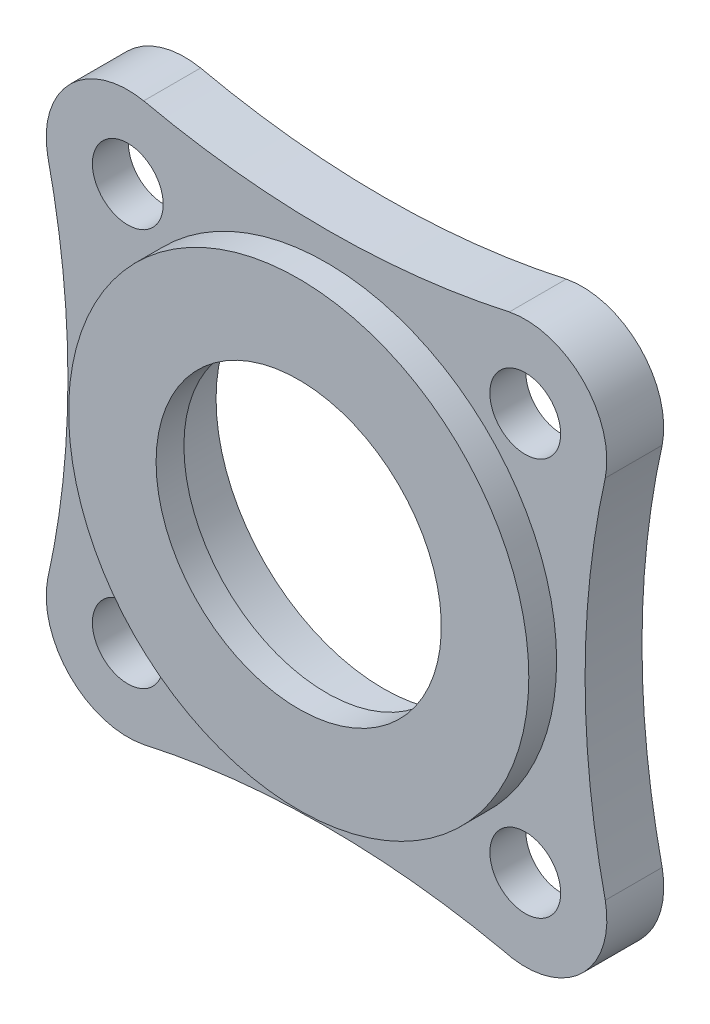
from build123d import *

# Parameters (mm, degrees)
SKETCH1_R           = 3.385
SKETCH1_R_2         = 16
BOSS_EXTRUDE1_DEPTH = 5.44
SKETCH2_R           = 6.5
CUT_EXTRUDE1_DEPTH  = 2
SKETCH3_R           = 22
BOSS_EXTRUDE2_DEPTH = 2.66
SKETCH4_R           = 13.635
CUT_EXTRUDE2_DEPTH  = 3.66


with BuildPart() as part:
    # Sketch1 → Boss-Extrude1 (new body)
    with BuildSketch(Plane.XY):
        with BuildLine():
            ThreePointArc((-17.15500238, -26.5786804), (-0.168836143, -24.722579211), (16.825003911, -26.507055409))
            ThreePointArc((16.825003911, -26.507055409), (24.281605458, -24.760439823), (26.649977107, -17.477419272))
            ThreePointArc((26.649977107, -17.477419272), (24.722401047, 0.0008954), (26.650274279, 17.479177295))
            ThreePointArc((26.650274279, 17.479177295), (24.514793015, 24.516072703), (17.477419272, 26.649977107))
            ThreePointArc((17.477419272, 26.649977107), (17.316247519, 26.614162818), (17.15500238, 26.5786804))
            ThreePointArc((17.15500238, 26.5786804), (0.000817995, 24.722401051), (-17.153414138, 26.578239095))
            ThreePointArc((-17.153414138, 26.578239095), (-17.316333175, 26.61408729), (-17.479177295, 26.650274279))
            ThreePointArc((-17.479177295, 26.650274279), (-24.516072703, 24.514793015), (-26.649977107, 17.477419272))
            ThreePointArc((-26.649977107, 17.477419272), (-24.722401047, -0.0008954), (-26.650274279, -17.479177295))
            ThreePointArc((-26.650274279, -17.479177295), (-24.514793015, -24.516072703), (-17.477419272, -26.649977107))
            ThreePointArc((-17.477419272, -26.649977107), (-17.316247519, -26.614162818), (-17.15500238, -26.5786804))
        make_face()
        with Locations((-18.999978097, -19.000021903)):
            Circle(SKETCH1_R, mode=Mode.SUBTRACT)
        with Locations((19.003521801, -19.017458637)):
            Circle(SKETCH1_R, mode=Mode.SUBTRACT)
        Circle(SKETCH1_R_2, mode=Mode.SUBTRACT)
        with Locations((-19.000021903, 18.999978097)):
            Circle(SKETCH1_R, mode=Mode.SUBTRACT)
        with Locations((18.999978097, 19.000021903)):
            Circle(SKETCH1_R, mode=Mode.SUBTRACT)
    extrude(amount=BOSS_EXTRUDE1_DEPTH)

    # Sketch2 → Cut-Extrude1 (cut)
    with BuildSketch(Plane(origin=(0, 0, 0), x_dir=(-1, 0, 0), z_dir=(0, 0, -1))):
        with Locations((19.000021903, 18.999978097)):
            Circle(SKETCH2_R)
        with Locations((-18.999978097, 19.000021903)):
            Circle(SKETCH2_R)
        with Locations((-19.003521801, -19.017458637)):
            Circle(SKETCH2_R)
        with Locations((18.999978097, -19.000021903)):
            Circle(SKETCH2_R)
    extrude(amount=-CUT_EXTRUDE1_DEPTH, mode=Mode.SUBTRACT)

    # Sketch3 → Boss-Extrude2 (add)
    with BuildSketch(Plane.XY.offset(5.44)):
        Circle(SKETCH3_R)
    extrude(amount=BOSS_EXTRUDE2_DEPTH)

    # Sketch4 → Cut-Extrude2 (cut, through all)
    with BuildSketch(Plane(origin=(0, 0, 5.44), x_dir=(-1, 0, 0), z_dir=(0, 0, -1))):
        Circle(SKETCH4_R)
    extrude(amount=-CUT_EXTRUDE2_DEPTH, mode=Mode.SUBTRACT)


solid = part.part
